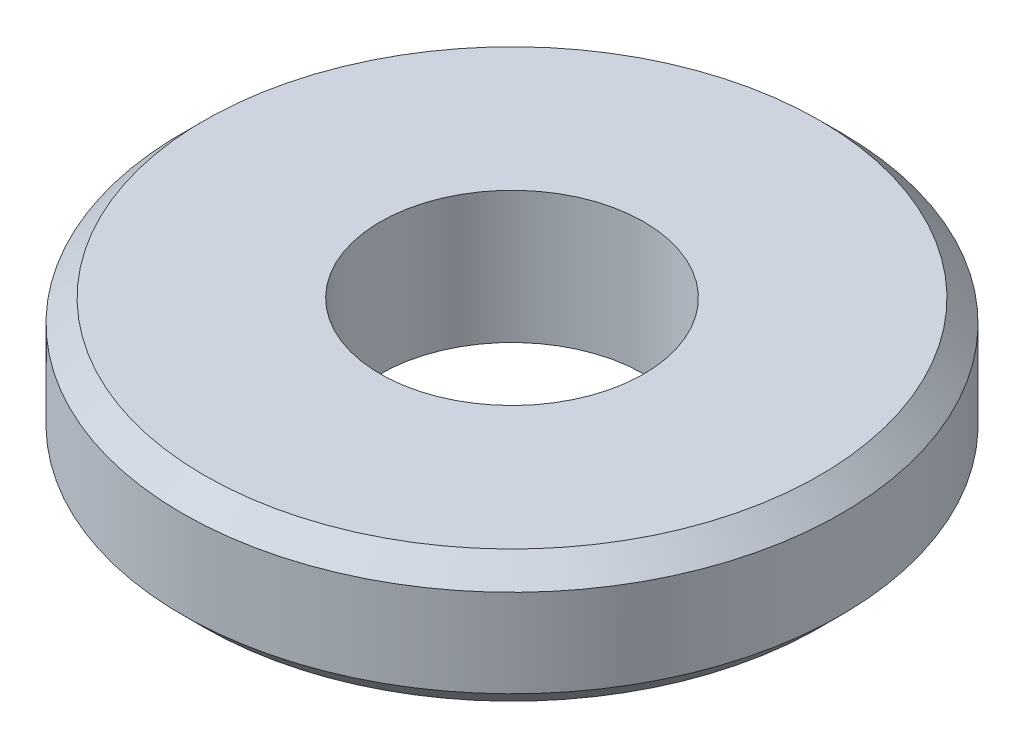
from build123d import *

# Parameters (mm, degrees)
SKETCH_1_W     = 9
SKETCH_1_H     = 6
CHAMFER_4_SIZE = 1


with BuildPart() as part:
    # Эскиз1 → Повернуть1 (revolve)
    with BuildSketch(Plane.XY):
        with Locations((10.5, 3)):
            Rectangle(SKETCH_1_W, SKETCH_1_H)
    revolve(axis=Axis((0, 0, 0), (0, 1, 0)))

    # Фаска4
    chamfer_4_edges = [part.edges().sort_by_distance(p)[0] for p in [
        (-15, 0, 0),
        (-15, 6, 0),
    ]]
    chamfer(chamfer_4_edges, length=CHAMFER_4_SIZE)


solid = part.part
